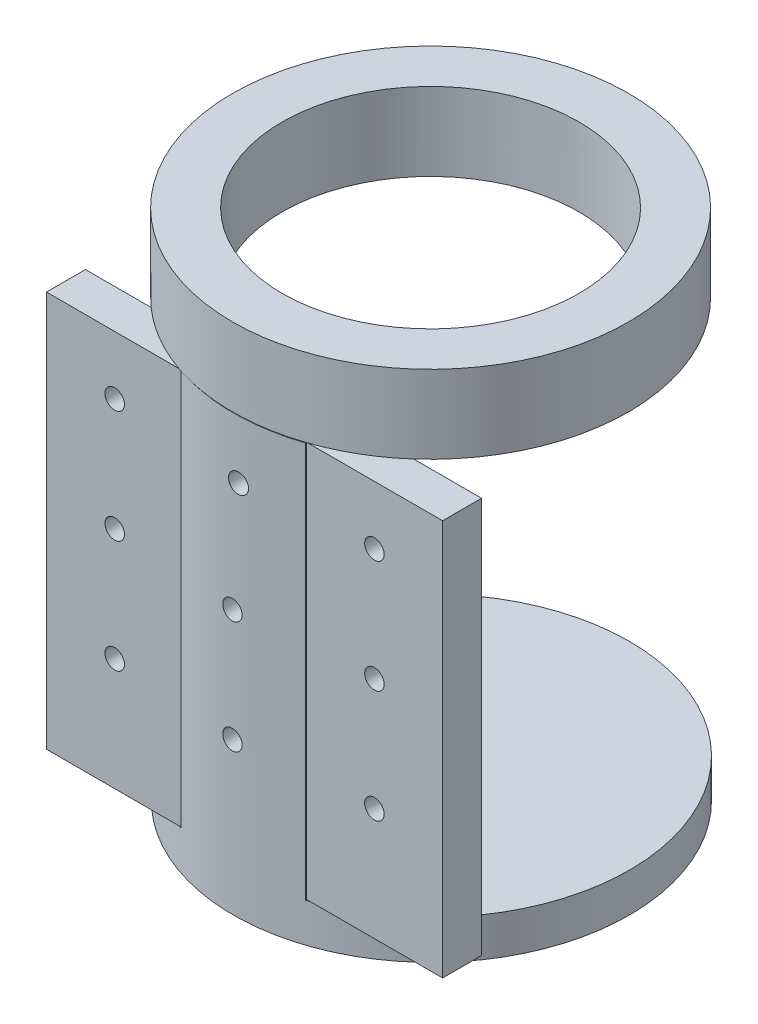
from build123d import *

# Parameters (mm, degrees)
SKETCH1_R               = 50.8
SKETCH1_R_2             = 38.1
BOSS_EXTRUDE1_DEPTH     = 20
SKETCH2_W               = 31.907935637
SKETCH2_H               = 10.300850003
BOSS_EXTRUDE2_DEPTH     = 101.6
BOSS_EXTRUDE3_DEPTH     = 101.6
SKETCH4_R               = 50.816877582
BOSS_EXTRUDE4_DEPTH     = 10
SKETCH6_W               = 34.862909764
SKETCH6_H               = 101.6
BOSS_EXTRUDE5_DEPTH     = 10
SKETCH7_W               = 34.862909764
SKETCH7_H               = 101.6
BOSS_EXTRUDE6_DEPTH     = 10
SKETCH8_R               = 2.5
CUT_EXTRUDE1_DEPTH      = 3.870178859
CUT_EXTRUDE1_DEPTH_BACK = 99.824625306
SKETCH10_R              = 5
CUT_EXTRUDE2_DEPTH      = 5.15
SKETCH11_R              = 2.5
CUT_EXTRUDE3_DEPTH      = 3.870178859
CUT_EXTRUDE3_DEPTH_BACK = 99.824625306
SKETCH12_R              = 5
CUT_EXTRUDE4_DEPTH      = 5.15
SKETCH13_R              = 2.5
CUT_EXTRUDE5_DEPTH      = 89.824625306
CUT_EXTRUDE5_DEPTH_BACK = 13.870178859
SKETCH14_R              = 5
CUT_EXTRUDE6_DEPTH      = 5.15


with BuildPart() as part:
    # Sketch1 → Boss-Extrude1 (new body)
    with BuildSketch(Plane(origin=(0, 0, 0), x_dir=(1, 0, 0), z_dir=(0, 1, 0))):
        Circle(SKETCH1_R)
        Circle(SKETCH1_R_2, mode=Mode.SUBTRACT)
    extrude(amount=BOSS_EXTRUDE1_DEPTH)

    # Sketch2 → Boss-Extrude2 (add)
    with BuildSketch(Plane.XZ):
        with Locations((0.29228093, 43.175050308)):
            Rectangle(SKETCH2_W, SKETCH2_H)
    extrude(amount=BOSS_EXTRUDE2_DEPTH)

    # Sketch3 → Boss-Extrude3 (add)
    with BuildSketch(Plane.XZ.offset(101.6)):
        with BuildLine():
            Line((-15.661686888, 48.325475309), (16.246248749, 48.325475309))
            ThreePointArc((16.246248749, 48.325475309), (0.292280931, 50.894804165), (-15.661686888, 48.325475309))
        make_face()
    extrude(amount=-BOSS_EXTRUDE3_DEPTH)

    # Sketch4 → Boss-Extrude4 (add)
    with BuildSketch(Plane.XZ.offset(101.6)):
        with Locations((0.292280931, 0.077926583)):
            Circle(SKETCH4_R)
    extrude(amount=BOSS_EXTRUDE4_DEPTH)

    # Sketch6 → Boss-Extrude5 (add)
    with BuildSketch(Plane(origin=(0, 0, 38.024625306), x_dir=(-1, 0, 0), z_dir=(0, 0, -1))):
        with Locations((33.09314177, -50.8)):
            Rectangle(SKETCH6_W, SKETCH6_H)
    extrude(amount=-BOSS_EXTRUDE5_DEPTH)

    # Sketch7 → Boss-Extrude6 (add)
    with BuildSketch(Plane(origin=(0, 0, 38.024625306), x_dir=(-1, 0, 0), z_dir=(0, 0, -1))):
        with Locations((-33.677703631, -50.8)):
            Rectangle(SKETCH7_W, SKETCH7_H)
    extrude(amount=-BOSS_EXTRUDE6_DEPTH)

    # Sketch8 → Cut-Extrude1 (cut, two sides)
    with BuildSketch(Plane.XY.offset(48.024625306)) as cut_extrude1_sk:
        with Locations((33.609158513, -15)):
            Circle(SKETCH8_R)
        with Locations((33.609158513, -43.86666666)):
            Circle(SKETCH8_R)
        with Locations((33.609158513, -72.733333333)):
            Circle(SKETCH8_R)
    extrude(amount=CUT_EXTRUDE1_DEPTH, mode=Mode.SUBTRACT)
    extrude(cut_extrude1_sk.sketch, amount=-CUT_EXTRUDE1_DEPTH_BACK, mode=Mode.SUBTRACT)

    # Sketch10 → Cut-Extrude2 (cut)
    with BuildSketch(Plane(origin=(0, 0, 38.024625306), x_dir=(-1, 0, 0), z_dir=(0, 0, -1))):
        with Locations((-33.609158513, -15)):
            Circle(SKETCH10_R)
        with Locations((-33.609158513, -43.86666666)):
            Circle(SKETCH10_R)
        with Locations((-33.609158513, -72.733333333)):
            Circle(SKETCH10_R)
    extrude(amount=-CUT_EXTRUDE2_DEPTH, mode=Mode.SUBTRACT)

    # Sketch11 → Cut-Extrude3 (cut, two sides)
    with BuildSketch(Plane.XY.offset(48.024625306)) as cut_extrude3_sk:
        with Locations((-33.024596652, -15)):
            Circle(SKETCH11_R)
        with Locations((-33.024596652, -43.866666667)):
            Circle(SKETCH11_R)
        with Locations((-33.024596652, -72.733333333)):
            Circle(SKETCH11_R)
    extrude(amount=CUT_EXTRUDE3_DEPTH, mode=Mode.SUBTRACT)
    extrude(cut_extrude3_sk.sketch, amount=-CUT_EXTRUDE3_DEPTH_BACK, mode=Mode.SUBTRACT)

    # Sketch12 → Cut-Extrude4 (cut)
    with BuildSketch(Plane(origin=(0, 0, 38.024625306), x_dir=(-1, 0, 0), z_dir=(0, 0, -1))):
        with Locations((33.024596652, -15)):
            Circle(SKETCH12_R)
        with Locations((33.024596652, -43.866666667)):
            Circle(SKETCH12_R)
        with Locations((33.024596652, -72.733333333)):
            Circle(SKETCH12_R)
    extrude(amount=-CUT_EXTRUDE4_DEPTH, mode=Mode.SUBTRACT)

    # Sketch13 → Cut-Extrude5 (cut, two sides)
    with BuildSketch(Plane(origin=(0, 0, 38.024625306), x_dir=(-1, 0, 0), z_dir=(0, 0, -1))) as cut_extrude5_sk:
        with Locations((-1.549603414, -15)):
            Circle(SKETCH13_R)
        with Locations((0, -43.866666667)):
            Circle(SKETCH13_R)
        with Locations((0, -72.733333333)):
            Circle(SKETCH13_R)
    extrude(amount=CUT_EXTRUDE5_DEPTH, mode=Mode.SUBTRACT)
    extrude(cut_extrude5_sk.sketch, amount=-CUT_EXTRUDE5_DEPTH_BACK, mode=Mode.SUBTRACT)

    # Sketch14 → Cut-Extrude6 (cut)
    with BuildSketch(Plane(origin=(0, 0, 38.024625306), x_dir=(-1, 0, 0), z_dir=(0, 0, -1))):
        with Locations((-1.549603414, -15)):
            Circle(SKETCH14_R)
        with Locations((0, -43.866666667)):
            Circle(SKETCH14_R)
        with Locations((0, -72.733333333)):
            Circle(SKETCH14_R)
    extrude(amount=-CUT_EXTRUDE6_DEPTH, mode=Mode.SUBTRACT)


solid = part.part
